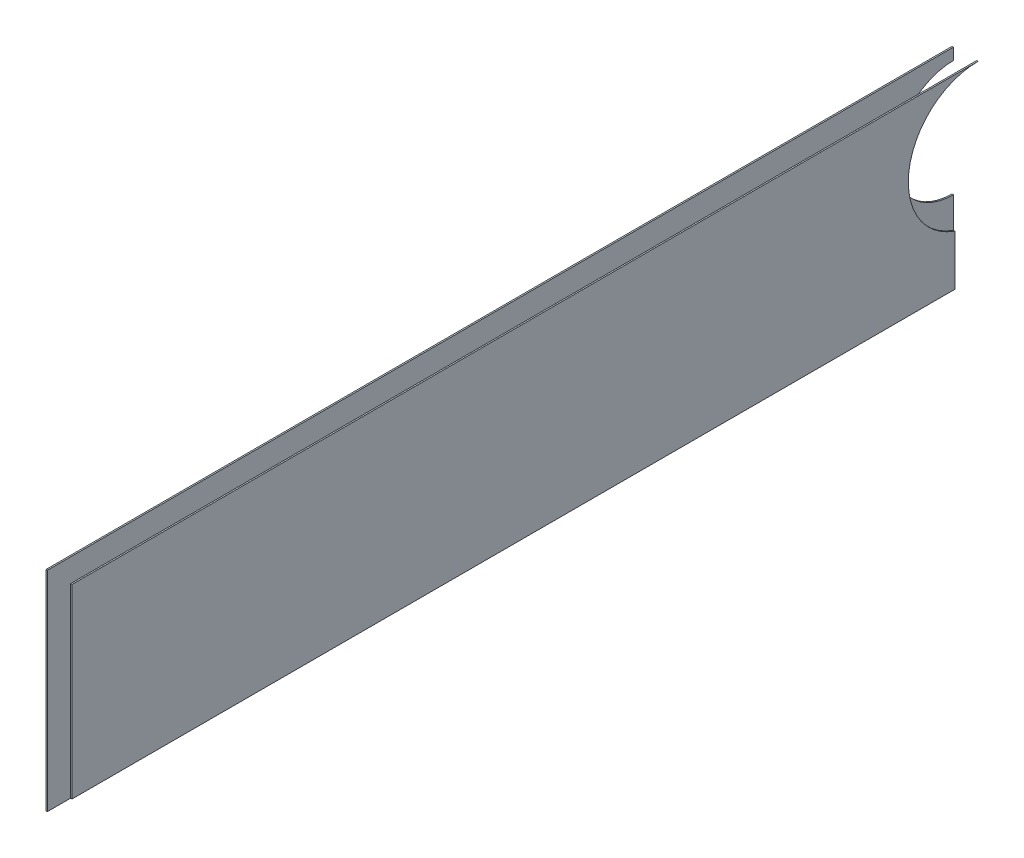
from build123d import *

# Parameters (mm, degrees)
DODANIE_WYCI_GNI_CIE1_DEPTH = 0.3
DODANIE_WYCI_GNI_CIE2_DEPTH = 0.3


with BuildPart() as part:
    # Szkic1 → Dodanie-wyciągnięcie1 (new body)
    with BuildSketch(Plane(origin=(-516.202987023, 0, 0), x_dir=(0, 0, -1), z_dir=(1, 0, 0))):
        with BuildLine():
            Line((-432.681641948, 705), (-242.681641948, 705))
            Line((-242.681641948, 705), (-242.681641948, 715.857864376))
            ThreePointArc((-242.681641948, 715.857864376), (-252.465620342, 732.536529681), (-237.681641948, 745))
            Line((-237.681641948, 745), (-432.681641948, 745))
            Line((-432.681641948, 745), (-432.681641948, 705))
        make_face()
    extrude(amount=DODANIE_WYCI_GNI_CIE1_DEPTH)


with BuildPart() as body_2:
    # Szkic2 → Dodanie-wyciągnięcie2 (new body)
    with BuildSketch(Plane.ZY.offset(521.202987023)):
        with BuildLine():
            Line((432.681641948, 700), (432.681641948, 745))
            Line((432.681641948, 745), (237.681641948, 745))
            Line((237.681641948, 745), (237.681641948, 742.5))
            ThreePointArc((237.681641948, 742.5), (250.181641948, 730), (237.681641948, 717.5))
            Line((237.681641948, 717.5), (237.681641948, 700))
            Line((237.681641948, 700), (432.681641948, 700))
        make_face()
    extrude(amount=DODANIE_WYCI_GNI_CIE2_DEPTH)


solid = Compound([part.part, body_2.part])
